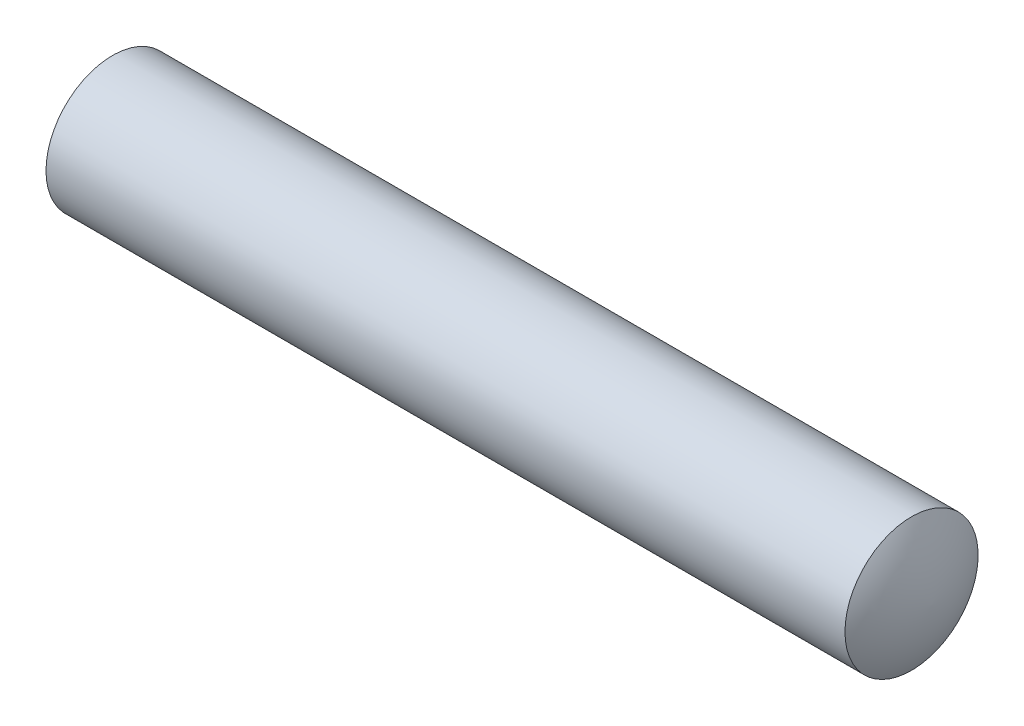
from build123d import *


with BuildPart() as part:
    # Эскиз1 → Повернуть2 (revolve)
    with BuildSketch(Plane.XY):
        with BuildLine():
            Line((0, 2), (24, 2))
            ThreePointArc((24, 2), (24.432805569, 1.039841671), (24.6, 0))
            Line((24.6, 0), (-0.6, 0))
            ThreePointArc((-0.6, 0), (-0.432805569, 1.039841671), (0, 2))
        make_face()
    revolve(axis=Axis((0, 0, 0), (1, 0, 0)))


solid = part.part
